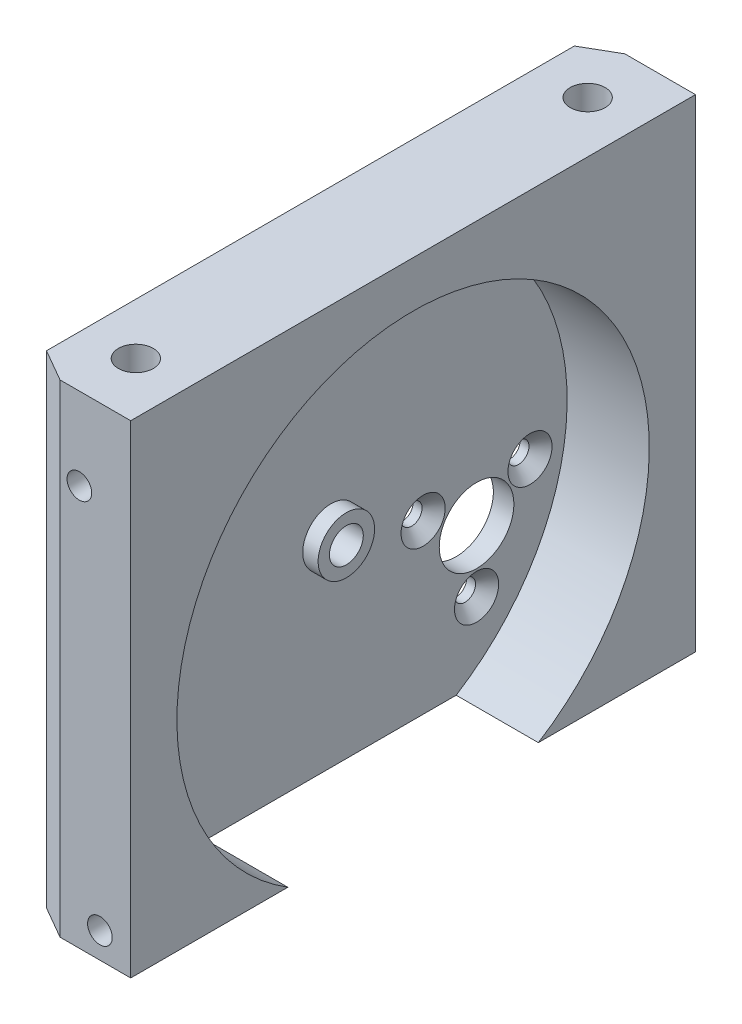
from build123d import *

# Parameters (mm, degrees)
SKETCH1_W                                    = 55
SKETCH1_H                                    = 47
EXTRUDE1_DEPTH                               = 10
SKETCH2_R                                    = 23
EXTRUDE2_DEPTH                               = 8
SKETCH3_R                                    = 1.2
EXTRUDE3_DEPTH                               = 6
SKETCH4_R                                    = 1.2
EXTRUDE4_DEPTH                               = 6
SKETCH5_R                                    = 2.75
SKETCH5_R_2                                  = 1.65
EXTRUDE5_DEPTH                               = 1.5
SKETCH6_R                                    = 1.65
EXTRUDE6_DEPTH                               = 2
SKETCH7_R                                    = 3.635
EXTRUDE7_DEPTH                               = 3
CSK_FOR_M1_6_COUNTERSUNK_FLAT_HEAD_S_2_COUNT = 2
CSK_FOR_M1_6_COUNTERSUNK_FLAT_HEAD_S_2_PITCH = 10.41
CSK_FOR_M1_6_COUNTERSUNK_FLAT_HEAD_S_3_COUNT = 2
CSK_FOR_M1_6_COUNTERSUNK_FLAT_HEAD_S_3_PITCH = 10.409719016
CHAMFER1_SIZE                                = 1.8
CHAMFER1_SIZE2                               = 3.117691454
F_3_4_3_4_DIAMETER_HOLE1_D                   = 3.4
F_3_4_3_4_DIAMETER_HOLE1_DEPTH               = 4
F_3_4_3_4_DIAMETER_HOLE1_TIP                 = 1.021463052


with BuildPart() as part:
    # Sketch1 → Extrude1 (new body)
    with BuildSketch(Plane(origin=(0, 0, 0), x_dir=(0, 0, -1), z_dir=(1, 0, 0))):
        with Locations((-14.681315866, 9.625451264)):
            Rectangle(SKETCH1_W, SKETCH1_H)
    extrude(amount=EXTRUDE1_DEPTH)

    # Sketch2 → Extrude2 (cut)
    with BuildSketch(Plane(origin=(10, 0, 0), x_dir=(0, 0, -1), z_dir=(1, 0, 0))):
        with Locations((-14.681315866, 5.625451264)):
            Circle(SKETCH2_R)
    extrude(amount=-EXTRUDE2_DEPTH, mode=Mode.SUBTRACT)

    # Sketch3 → Extrude3 (cut)
    with BuildSketch(Plane.XY.offset(42.181315866)):
        with Locations((5, 25.125451264)):
            Circle(SKETCH3_R)
        with Locations((7, -11.374548736)):
            Circle(SKETCH3_R)
    extrude(amount=-EXTRUDE3_DEPTH, mode=Mode.SUBTRACT)

    # Sketch4 → Extrude4 (cut)
    with BuildSketch(Plane(origin=(0, 0, -12.818684134), x_dir=(-1, 0, 0), z_dir=(0, 0, -1))):
        with Locations((-5, 25.125451264)):
            Circle(SKETCH4_R)
        with Locations((-7, -11.374548736)):
            Circle(SKETCH4_R)
    extrude(amount=-EXTRUDE4_DEPTH, mode=Mode.SUBTRACT)

    # Sketch5 → Extrude5 (add)
    with BuildSketch(Plane(origin=(2, 0, 0), x_dir=(0, 0, -1), z_dir=(1, 0, 0))):
        with Locations((-14.681315866, 5.625451264)):
            Circle(SKETCH5_R)
        with Locations((-14.681315866, 5.625451264)):
            Circle(SKETCH5_R_2, mode=Mode.SUBTRACT)
    extrude(amount=EXTRUDE5_DEPTH)

    # Sketch6 → Extrude6 (cut)
    with BuildSketch(Plane(origin=(2, 0, 0), x_dir=(0, 0, -1), z_dir=(1, 0, 0))):
        with Locations((-14.681315866, 5.625451264)):
            Circle(SKETCH6_R)
    extrude(amount=-EXTRUDE6_DEPTH, mode=Mode.SUBTRACT)

    # Sketch7 → Extrude7 (cut)
    with BuildSketch(Plane.ZY):
        with Locations((0.501315866, -0.554548736)):
            Circle(SKETCH7_R)
    extrude(amount=-EXTRUDE7_DEPTH, mode=Mode.SUBTRACT)

    # Sketch10 → CSK for M1.6 Countersunk Flat Head Screw1 (revolve, cut)
    with BuildSketch(Plane(origin=(2, 2.450451264, 5.706315866), x_dir=(0, 0, -1), z_dir=(0, 1, 0))):
        Polygon((0, 0), (0, 2), (1.025, 2), (1.025, 1.125), (2.15, 0), align=None)
    csk_for_m1_6_countersunk_flat_head_screw = revolve(axis=Axis((8.35, 2.450451264, 5.706315866), (-1, 0, 0)), mode=Mode.SUBTRACT)

    # CSK for M1.6 Countersunk Flat Head S 2: CSK for M1.6 Countersunk Flat Head Screw1 ×2
    with Locations(*[(0, 0, -i * CSK_FOR_M1_6_COUNTERSUNK_FLAT_HEAD_S_2_PITCH) for i in range(1, CSK_FOR_M1_6_COUNTERSUNK_FLAT_HEAD_S_2_COUNT)]):
        add(csk_for_m1_6_countersunk_flat_head_screw, mode=Mode.SUBTRACT)

    # CSK for M1.6 Countersunk Flat Head S 3: CSK for M1.6 Countersunk Flat Head Screw1 ×2
    with Locations(*[Vector(0, -0.866017612, -0.500013496) * (i * CSK_FOR_M1_6_COUNTERSUNK_FLAT_HEAD_S_3_PITCH) for i in range(1, CSK_FOR_M1_6_COUNTERSUNK_FLAT_HEAD_S_3_COUNT)]):
        add(csk_for_m1_6_countersunk_flat_head_screw, mode=Mode.SUBTRACT)

    # Chamfer1
    chamfer1_edges = [part.edges().sort_by_distance(p)[0] for p in [
        (0, 9.625451264, -12.818684134),
        (0, 9.625451264, 42.181315866),
    ]]
    chamfer1_side = [part.faces().sort_by_distance(p)[0] for p in [
        (0, 9.84627635, 14.970036249),
    ]]
    chamfer(chamfer1_edges, length=CHAMFER1_SIZE, length2=CHAMFER1_SIZE2, reference=chamfer1_side[0])

    # Ø3.4 (3.4) Diameter Hole1
    with Locations(Plane(origin=(5, 33.125451264, -7.318684134), x_dir=(0, 0, 1), z_dir=(0, 1, 0))):
        with Locations((0, 0), (44, 0)):
            Hole(F_3_4_3_4_DIAMETER_HOLE1_D / 2, depth=F_3_4_3_4_DIAMETER_HOLE1_DEPTH)
            with Locations((0, 0, -(F_3_4_3_4_DIAMETER_HOLE1_DEPTH + F_3_4_3_4_DIAMETER_HOLE1_TIP / 2))):  # 118° drill point
                Cone(0, F_3_4_3_4_DIAMETER_HOLE1_D / 2, F_3_4_3_4_DIAMETER_HOLE1_TIP, mode=Mode.SUBTRACT)


solid = part.part
